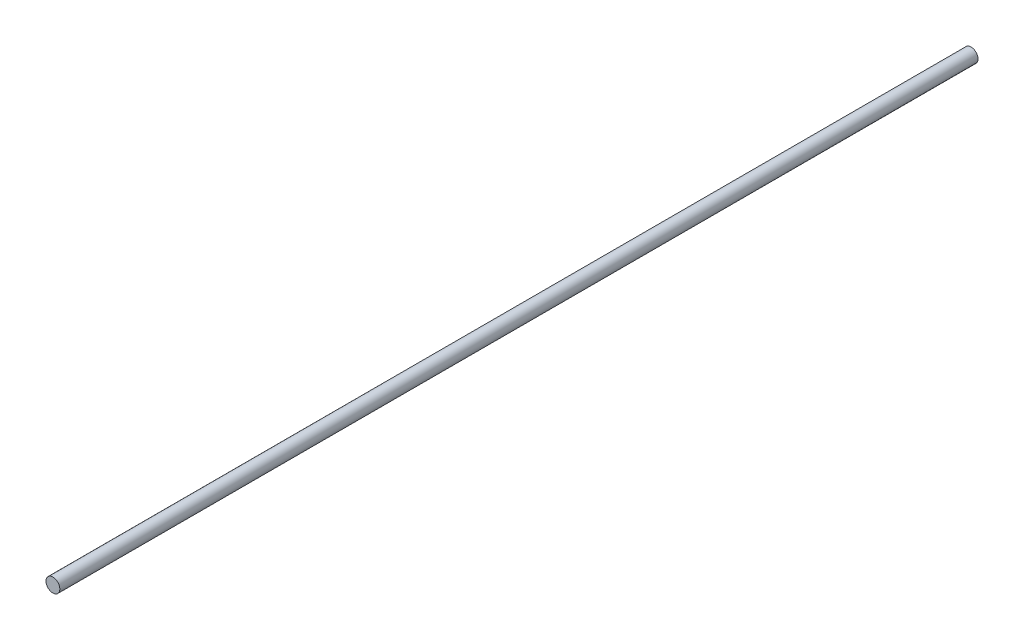
from build123d import *

# Parameters (mm, degrees)
SKETCH1_R           = 3.96875
BOSS_EXTRUDE1_DEPTH = 263.525


with BuildPart() as part:
    # Sketch1 → Boss-Extrude1 (new body, symmetric)
    with BuildSketch(Plane.XY):
        Circle(SKETCH1_R)
    extrude(amount=BOSS_EXTRUDE1_DEPTH, both=True)


solid = part.part
